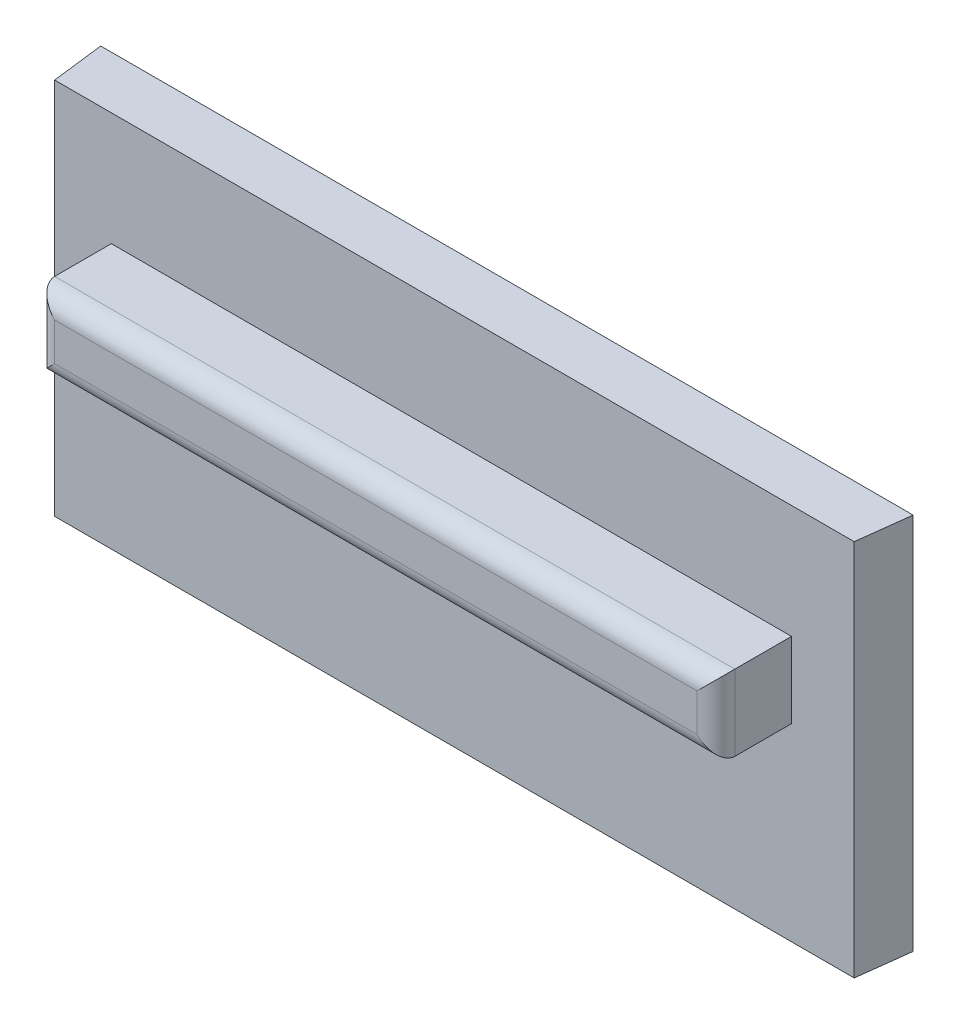
from build123d import *

# Parameters (mm, degrees)
RESSALTO_EXTRUS_O1_DEPTH = 10
ESBO_O4_W                = 18
ESBO_O4_H                = 2
RESSALTO_EXTRUS_O2_DEPTH = 2
FILETE1_R                = 0.5


with BuildPart() as part:
    # Esboço3 → Ressalto-extrusão1 (new body)
    with BuildSketch(Plane(origin=(0, 0, 0), x_dir=(1, 0, 0), z_dir=(0, 1, 0))):
        Polygon((21.574658441, 89.694736978), (21.745275522, 91.08430159), (0.245275522, 91.08430159), (0.415892603, 89.694736978), align=None)
    extrude(amount=RESSALTO_EXTRUS_O1_DEPTH)

    # Esboço4 → Ressalto-extrusão2 (add)
    with BuildSketch(Plane.XY.offset(-89.694736978)):
        with Locations((10.915892603, 6)):
            Rectangle(ESBO_O4_W, ESBO_O4_H)
    extrude(amount=RESSALTO_EXTRUS_O2_DEPTH)

    # Filete1
    filete1_edges = [part.edges().sort_by_distance(p)[0] for p in [
        (1.915892603, 6, -87.694736978),
        (10.915892603, 5, -87.694736978),
        (19.915892603, 6, -87.694736978),
        (10.915892603, 7, -87.694736978),
    ]]
    fillet(filete1_edges, radius=FILETE1_R)


solid = part.part
